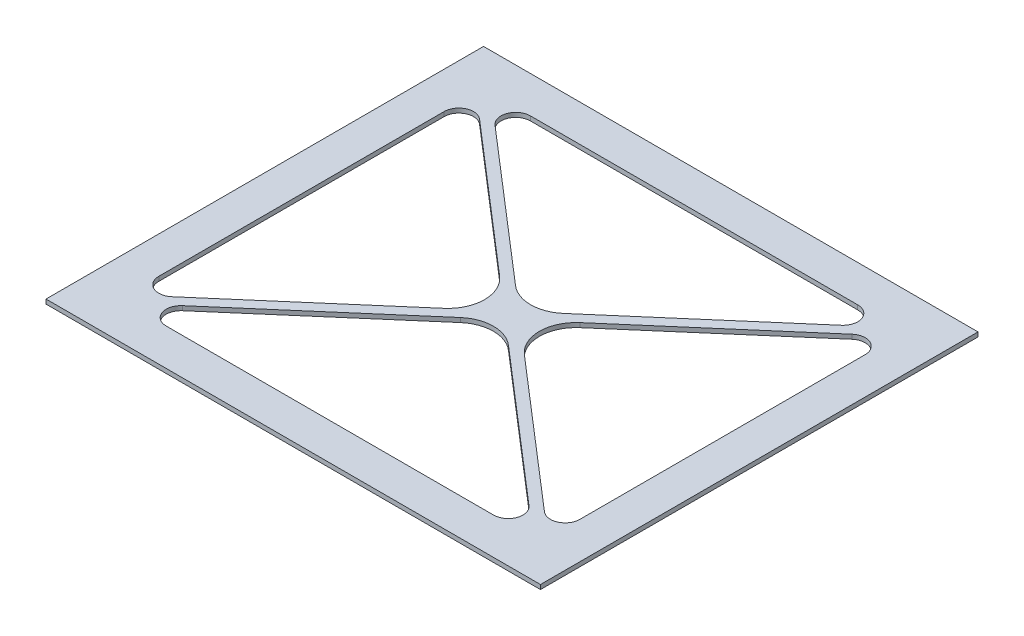
from build123d import *

# Parameters (mm, degrees)
SKETCH1_W           = 134.7
SKETCH1_H           = 119.2
BOSS_EXTRUDE1_DEPTH = 1.2
FILLET1_R           = 10
FILLET2_R           = 4


with BuildPart() as part:
    # Sketch1 → Boss-Extrude1 (new body)
    with BuildSketch(Plane(origin=(0, 0, 0), x_dir=(1, 0, 0), z_dir=(0, 1, 0))):
        with Locations((67.35, 59.6)):
            Rectangle(SKETCH1_W, SKETCH1_H)
        Polygon((122.7, 109.2), (67.35, 61.462466726), (12, 109.2), align=None, mode=Mode.SUBTRACT)
        Polygon((10, 107.2), (10, 12), (65.190534979, 59.6), align=None, mode=Mode.SUBTRACT)
        Polygon((12, 10), (122.7, 10), (67.35, 57.737533274), align=None, mode=Mode.SUBTRACT)
        Polygon((124.7, 107.2), (124.7, 12), (69.509465021, 59.6), align=None, mode=Mode.SUBTRACT)
    extrude(amount=BOSS_EXTRUDE1_DEPTH)

    # Fillet1
    fillet1_edges = [part.edges().sort_by_distance(p)[0] for p in [
        (67.35, 0.6, -61.462466726),
        (65.190534979, 0.6, -59.6),
        (67.35, 0.6, -57.737533274),
        (69.509465021, 0.6, -59.6),
    ]]
    fillet(fillet1_edges, radius=FILLET1_R)

    # Fillet2
    fillet2_edges = [part.edges().sort_by_distance(p)[0] for p in [
        (12, 0.6, -109.2),
        (122.7, 0.6, -109.2),
        (10, 0.6, -107.2),
        (10, 0.6, -12),
        (122.7, 0.6, -10),
        (12, 0.6, -10),
        (124.7, 0.6, -107.2),
        (124.7, 0.6, -12),
    ]]
    fillet(fillet2_edges, radius=FILLET2_R)


solid = part.part
